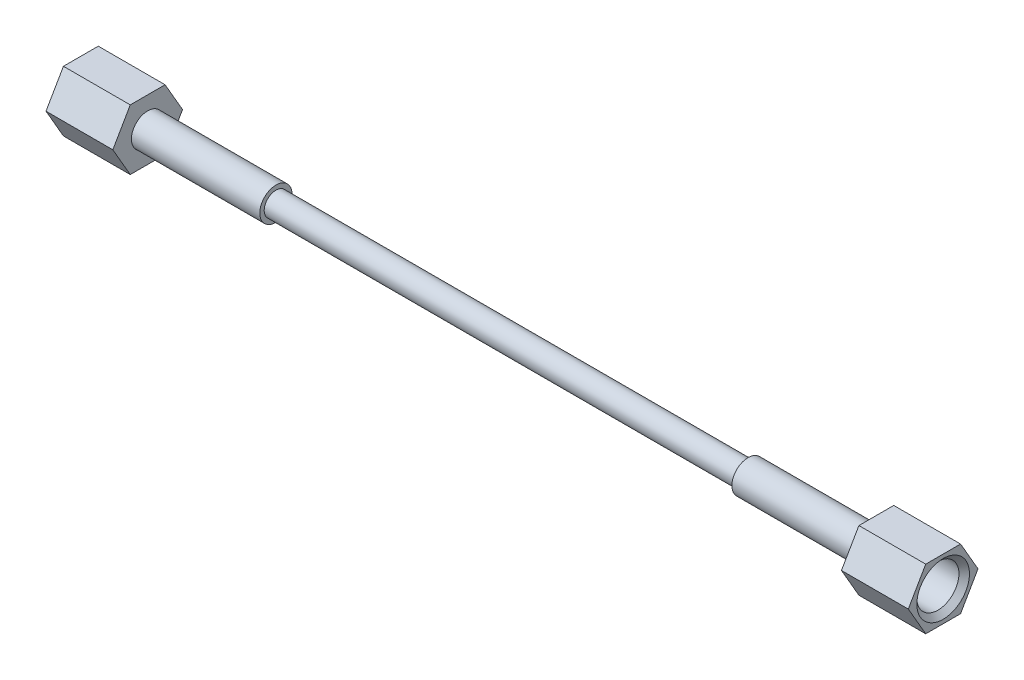
from build123d import *

# Parameters (mm, degrees)
EXTRUDE2_DEPTH = 15.748
CHAMFER2_SIZE  = 1.240155


with BuildPart() as part:
    # Sketch5 → Extrude2 (new body)
    with BuildSketch(Plane(origin=(-6.858, 0, 0), x_dir=(0, 0, -1), z_dir=(1, 0, 0))):
        Polygon((4.106115114, 7.112), (-4.106115114, 7.112), (-8.212230229, 0), (-4.106115114, -7.112), (4.106115114, -7.112), (8.212230229, 0), align=None)
    extrude(amount=EXTRUDE2_DEPTH)

    # Sketch6 → Hole2 (revolve, cut)
    with BuildSketch(Plane(origin=(8.89, 0, 0), x_dir=(0, 0, -1), z_dir=(0, 1, 0))):
        Polygon((0, 0), (0, 15.748), (3.8354, 15.748), (3.8354, 9.566100386), (4.96062, 8.89), (4.96062, 0), align=None)
    revolve(axis=Axis((15.020023899, 0, 0), (-1, 0, 0)), mode=Mode.SUBTRACT)

    # Chamfer2
    chamfer2_edges = [part.edges().sort_by_distance(p)[0] for p in [
        (8.89, 0, 4.96062),
    ]]
    chamfer(chamfer2_edges, length=CHAMFER2_SIZE)


with BuildPart() as body_2:
    # Sketch8 → Revolve2 (revolve)
    with BuildSketch(Plane(origin=(0, 0, 0), x_dir=(-1, 0, 0), z_dir=(0, 0, -1)), mode=Mode.PRIVATE) as revolve2_sk:
        Polygon((0.691362245, 3.81), (2.385428675, 0.9906), (183.034571325, 0.9906), (184.728637755, 3.81), (148.336, 3.81), (148.336, 2.7686), (37.084, 2.7686), (37.084, 3.81), align=None)
    revolve(revolve2_sk.sketch.rotate(Axis((-0.691362245, 0, 0), (-1, 0, 0)), 270), axis=Axis((-0.691362245, 0, 0), (-1, 0, 0)))  # turned: the seam where the file's is


with BuildPart() as body_3:
    # Mirror2: mirrored copy
    add(part.part.mirror(Plane(origin=(-92.71, 0, 0), x_dir=(0, 0, 1), z_dir=(1, 0, 0))))


solid = Compound([part.part, body_2.part, body_3.part])
